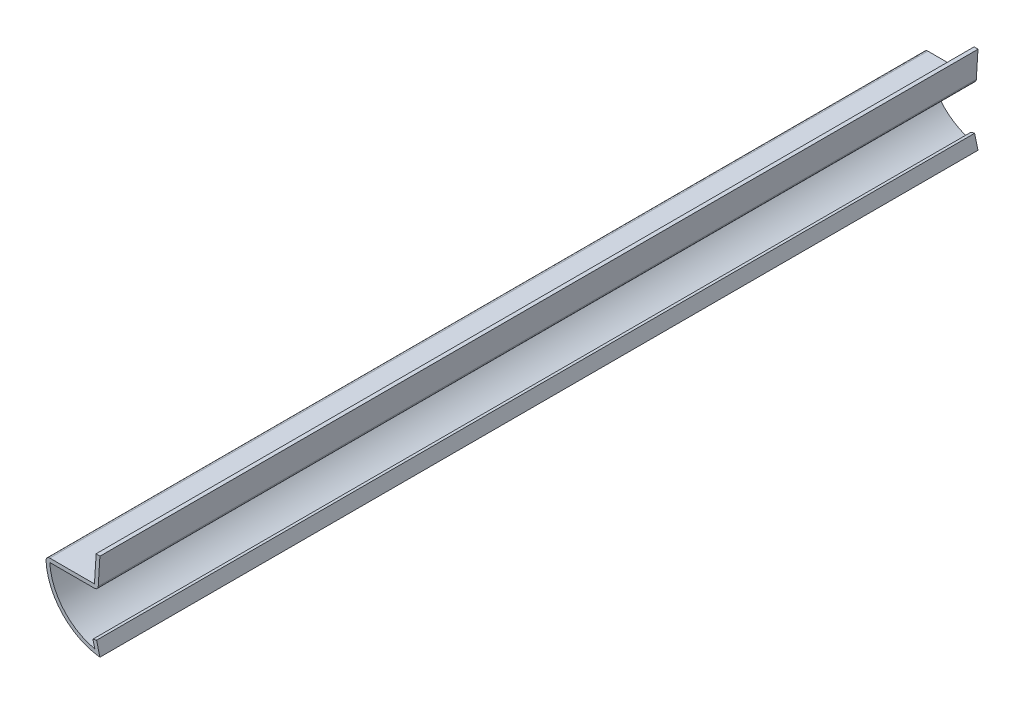
from build123d import *

# Parameters (mm, degrees)
EXTRUDE_THIN1_DEPTH = 206.375
FILLET1_R           = 0.889


with BuildPart() as part:
    # Sketch1 → Extrude-Thin1 (new body)
    with BuildSketch(Plane.XY):
        with BuildLine():
            Line((-0.79375, 3.074180531), (0, 0))
            ThreePointArc((0, 0), (-9.091384352, 4.706963909), (-12.7, 14.2875))
            Line((-12.7, 14.2875), (-1.285875, 14.2875))
            Line((-1.285875, 14.2875), (-0.889, 20.625085521))
            Line((-0.889, 20.625085521), (-0.001738027, 20.569523021))
            Line((-0.001738027, 20.569523021), (-0.450804908, 13.3985))
            Line((-0.450804908, 13.3985), (-11.787335474, 13.3985))
            ThreePointArc((-11.787335474, 13.3985), (-8.569392416, 5.460475486), (-1.20057239, 1.093796873))
            Line((-1.20057239, 1.093796873), (-1.654520549, 2.851930531))
            Line((-1.654520549, 2.851930531), (-0.79375, 3.074180531))
        make_face()
    extrude(amount=-EXTRUDE_THIN1_DEPTH)

    # Fillet1
    fillet1_edges = [part.edges().sort_by_distance(p)[0] for p in [
        (-0.450804908, 13.3985, -103.1875),
        (-12.7, 14.2875, -103.1875),
    ]]
    fillet(fillet1_edges, radius=FILLET1_R)


solid = part.part
